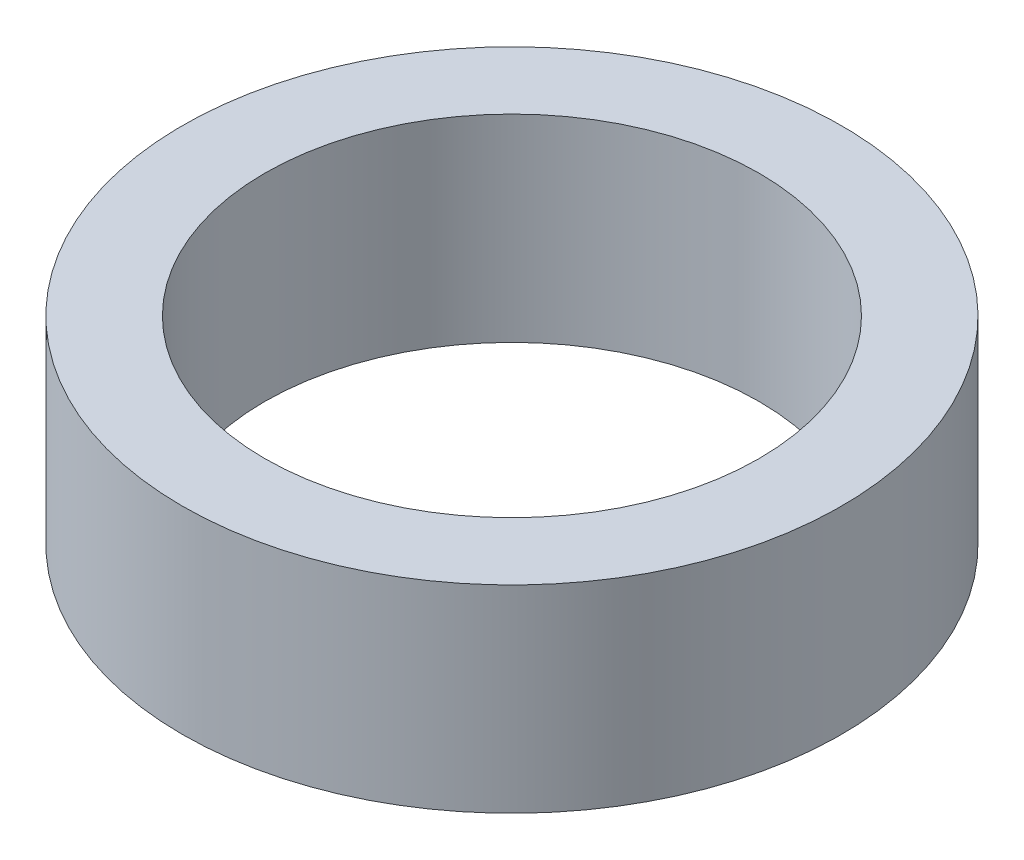
from build123d import *

# Parameters (mm, degrees)
SKETCH1_R           = 20
SKETCH1_R_2         = 15
BOSS_EXTRUDE1_DEPTH = 12


with BuildPart() as part:
    # Sketch1 → Boss-Extrude1 (new body)
    with BuildSketch(Plane(origin=(0, 0, 0), x_dir=(1, 0, 0), z_dir=(0, 1, 0))):
        Circle(SKETCH1_R)
        Circle(SKETCH1_R_2, mode=Mode.SUBTRACT)
    extrude(amount=BOSS_EXTRUDE1_DEPTH)


solid = part.part
